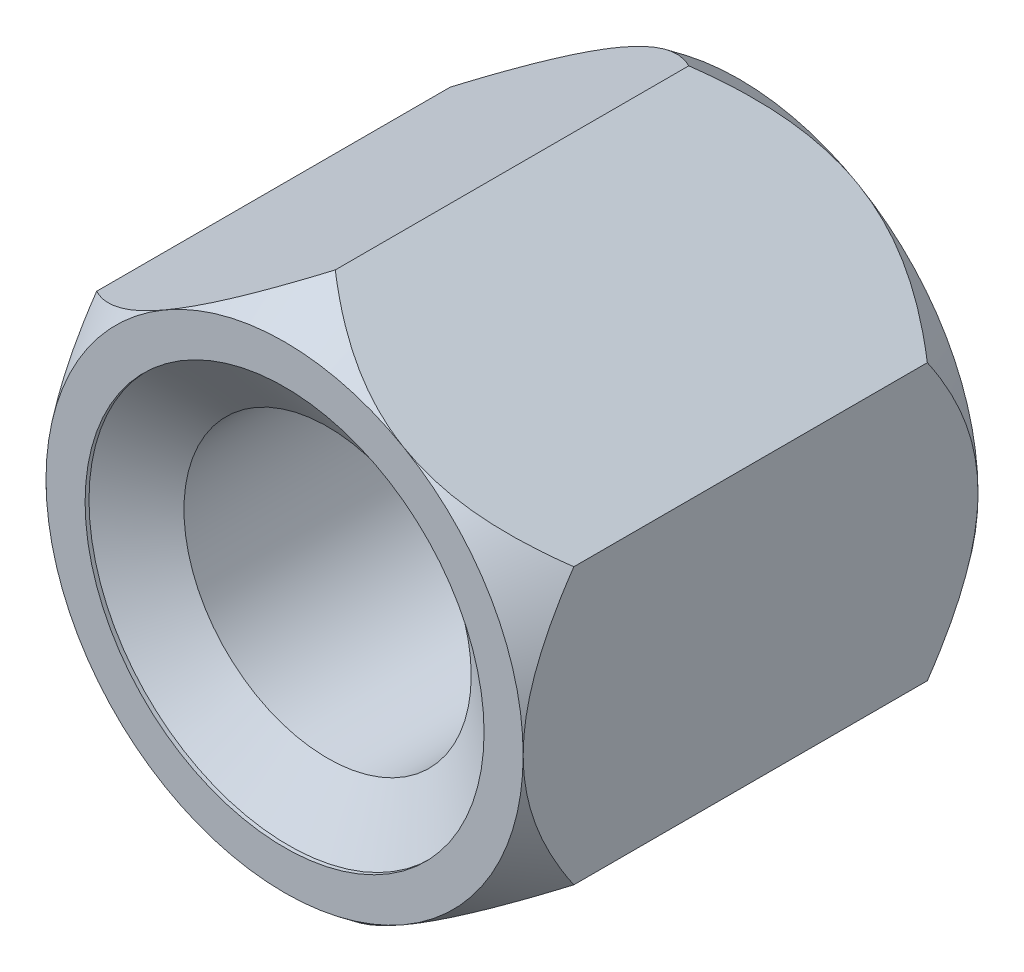
from build123d import *

# Parameters (mm, degrees)
BASENUTSKE_R  = 1.8
BASENUT_DEPTH = 5.7


with BuildPart() as part:
    # BaseNutSke → BaseNut (new body)
    with BuildSketch(Plane.XY):
        Polygon((2.99, 1.726277305), (2.99, -1.726277305), (0, -3.45255461), (-2.99, -1.726277305), (-2.99, 1.726277305), (0, 3.45255461), align=None)
        Circle(BASENUTSKE_R, mode=Mode.SUBTRACT)
    extrude(amount=-BASENUT_DEPTH)

    # Sketch3 → Double-Chamfer (revolve, cut)
    with BuildSketch(Plane(origin=(0, 0, 0), x_dir=(0, 0, -1), z_dir=(1, 0, 0))):
        Polygon((5.7, 2.99), (5.065, 3.45255461), (5.065, 16.15255461), (18.4, 16.15255461), (18.4, 2.99), align=None)
        Polygon((0.635, 16.15255461), (-12.7, 16.15255461), (-12.7, 2.99), (0, 2.99), (0.635, 3.45255461), align=None)
    revolve(axis=Axis((0, 0, 0), (0, 0, -1)), mode=Mode.SUBTRACT)

    # Sketch5 → EndChamfer (revolve, cut)
    with BuildSketch(Plane(origin=(0, 0, 0), x_dir=(0, 0, -1), z_dir=(1, 0, 0))):
        Polygon((5.6502, 2.5), (4.591136098, 0.9875), (5.701, 0.9875), (5.701, 2.5), align=None)
        Polygon((-0.002, 2.5), (0.0488, 2.5), (1.107863902, 0.9875), (-0.002, 0.9875), align=None)
    revolve(axis=Axis((0, 0, -25.037505729), (0, 0, -1)), mode=Mode.SUBTRACT)


solid = part.part
